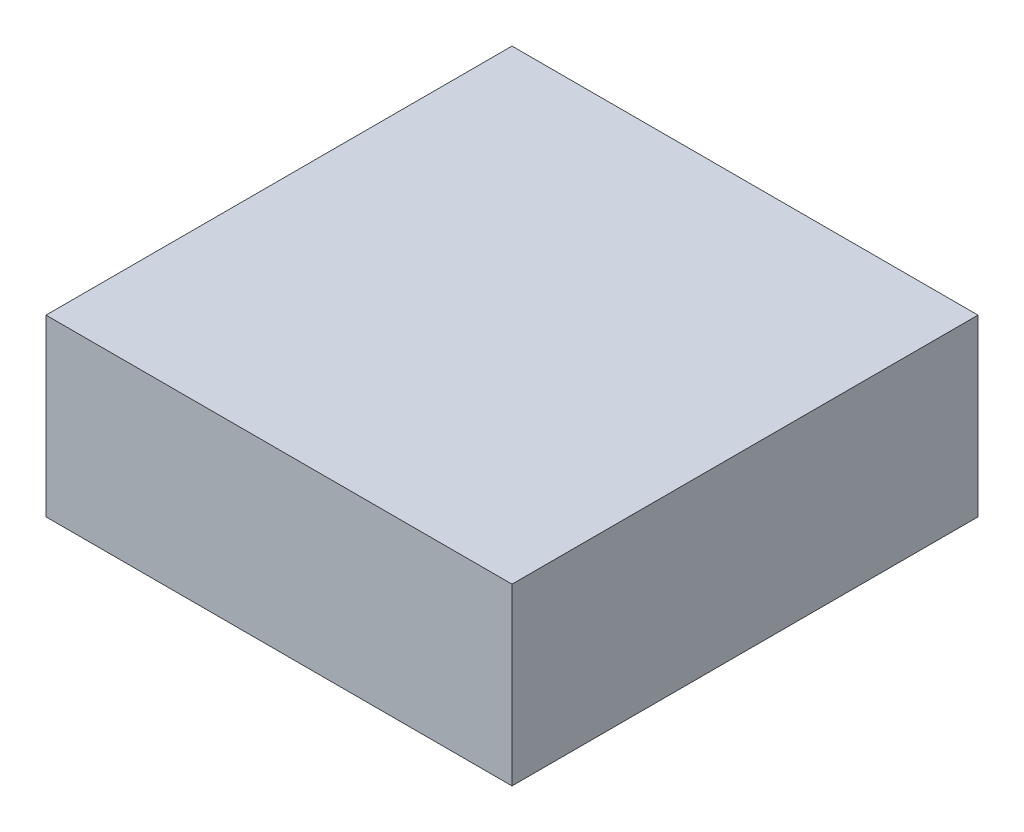
from build123d import *

# Parameters (mm, degrees)
SKETCH3_W           = 1219.2
SKETCH3_H           = 1219.2
BOSS_EXTRUDE1_DEPTH = 457.2


with BuildPart() as part:
    # Sketch3 → Boss-Extrude1 (new body)
    with BuildSketch(Plane(origin=(0, 0, 0), x_dir=(1, 0, 0), z_dir=(0, 1, 0))):
        Rectangle(SKETCH3_W, SKETCH3_H)
    extrude(amount=BOSS_EXTRUDE1_DEPTH)


solid = part.part
